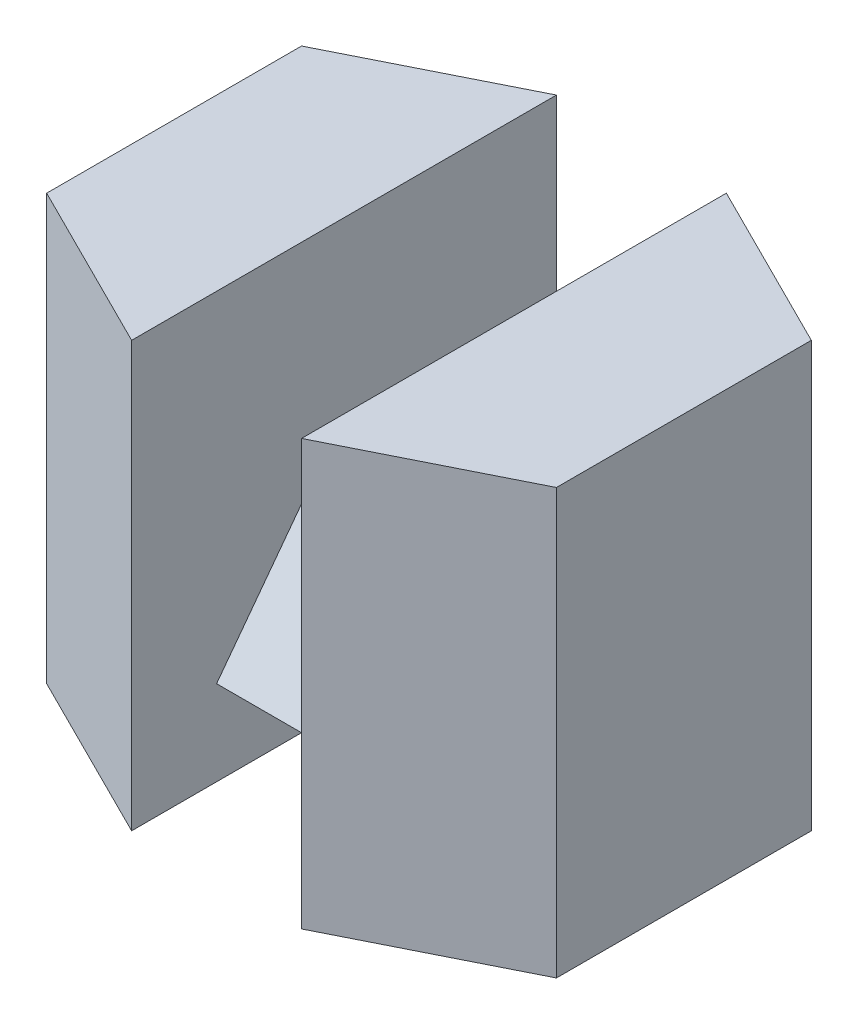
from build123d import *

# Parameters (mm, degrees)
SKETCH1_W           = 10
SKETCH1_H           = 25
BOSS_EXTRUDE1_DEPTH = 25
CUT_EXTRUDE1_DEPTH  = 25
SKETCH3_W           = 15
SKETCH3_H           = 10
BOSS_EXTRUDE2_DEPTH = 10
CUT_EXTRUDE2_DEPTH  = 10
SKETCH5_W           = 25
SKETCH5_H           = 25
BOSS_EXTRUDE3_DEPTH = 10
CUT_EXTRUDE3_DEPTH  = 25


with BuildPart() as part:
    # Sketch1 → Boss-Extrude1 (new body)
    with BuildSketch(Plane.XY):
        with Locations((5, 12.5)):
            Rectangle(SKETCH1_W, SKETCH1_H)
    extrude(amount=BOSS_EXTRUDE1_DEPTH)

    # Sketch2 → Cut-Extrude1 (cut)
    with BuildSketch(Plane(origin=(0, 25, 0), x_dir=(1, 0, 0), z_dir=(0, 1, 0))):
        Polygon((0, 0), (10, 0), (10, -5), align=None)
        Polygon((0, -25), (10, -20), (10, -25), align=None)
    extrude(amount=-CUT_EXTRUDE1_DEPTH, mode=Mode.SUBTRACT)

    # Sketch3 → Boss-Extrude2 (add)
    with BuildSketch(Plane.ZY):
        with Locations((12.5, 10)):
            Rectangle(SKETCH3_W, SKETCH3_H)
    extrude(amount=BOSS_EXTRUDE2_DEPTH)

    # Sketch4 → Cut-Extrude2 (cut)
    with BuildSketch(Plane.ZY.offset(10)):
        Polygon((20, 15), (12.5, 15), (20, 5), align=None)
        Polygon((5, 15), (5, 5), (12.5, 15), align=None)
    extrude(amount=-CUT_EXTRUDE2_DEPTH, mode=Mode.SUBTRACT)

    # Sketch5 → Boss-Extrude3 (add)
    with BuildSketch(Plane.ZY.offset(10)):
        with Locations((12.5, 12.5)):
            Rectangle(SKETCH5_W, SKETCH5_H)
    extrude(amount=BOSS_EXTRUDE3_DEPTH)

    # Sketch6 → Cut-Extrude3 (cut)
    with BuildSketch(Plane(origin=(0, 25, 0), x_dir=(1, 0, 0), z_dir=(0, 1, 0))):
        Polygon((-10, 0), (-20, 0), (-20, -5), align=None)
        Polygon((-20, -25), (-20, -20), (-10, -25), align=None)
    extrude(amount=-CUT_EXTRUDE3_DEPTH, mode=Mode.SUBTRACT)


solid = part.part
